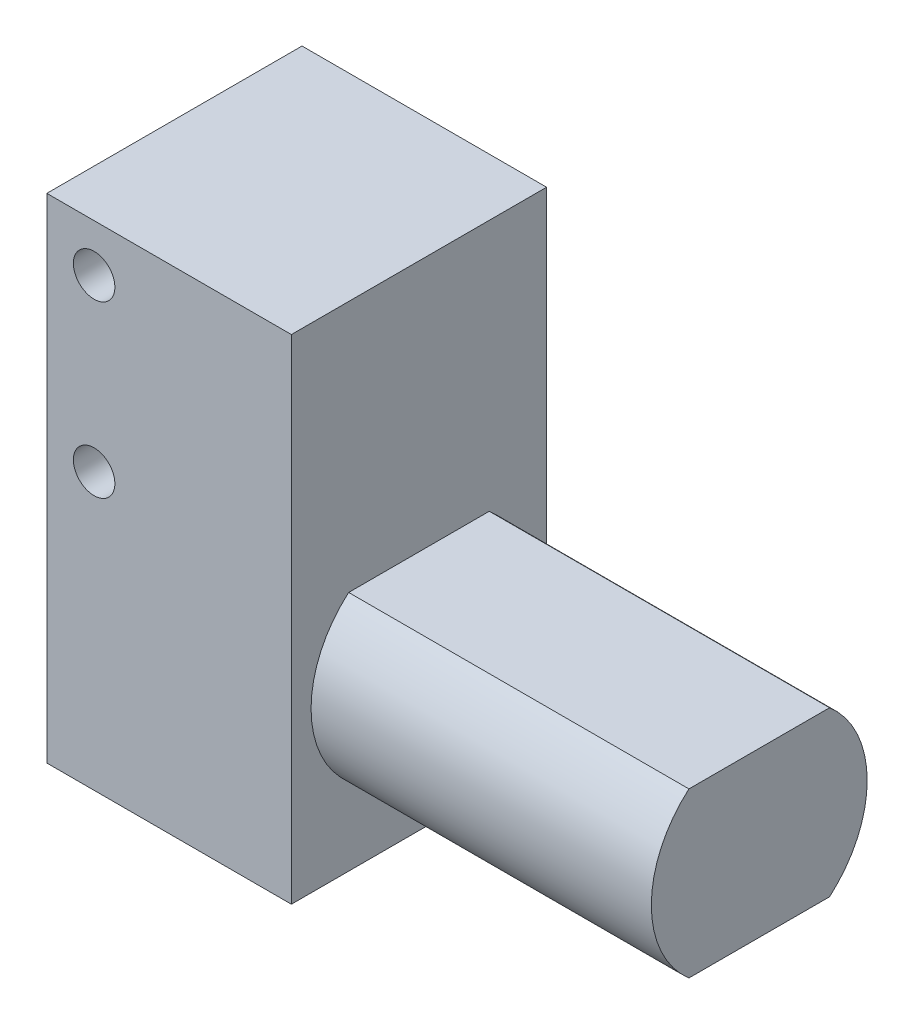
from build123d import *

# Parameters (mm, degrees)
SKETCH1_W               = 23
SKETCH1_H               = 46.4
BOSS_EXTRUDE1_DEPTH     = 12
SKETCH6_R               = 1.95
CUT_EXTRUDE1_DEPTH      = 5.5
SKETCH7_R               = 2.7
BOSS_EXTRUDE2_DEPTH     = 9
SKETCH8_W               = 7
SKETCH8_H               = 0.95
CUT_EXTRUDE2_DEPTH      = 47.4
SKETCH9_R               = 1.95
CUT_EXTRUDE3_DEPTH      = 5.5
SKETCH10_R              = 10.15
BOSS_EXTRUDE3_DEPTH     = 32
SKETCH11_W              = 32
SKETCH11_H              = 2.45
CUT_EXTRUDE4_DEPTH      = 13
CUT_EXTRUDE4_DEPTH_BACK = 13
SKETCH12_W              = 3
SKETCH12_H              = 9
CUT_EXTRUDE5_DEPTH      = 5


with BuildPart() as part:
    # Sketch1 → Boss-Extrude1 (new body, symmetric)
    with BuildSketch(Plane.XY):
        with Locations((11.5, 23.2)):
            Rectangle(SKETCH1_W, SKETCH1_H)
    extrude(amount=BOSS_EXTRUDE1_DEPTH, both=True)

    # Sketch6 → Cut-Extrude1 (cut)
    with BuildSketch(Plane.XY.offset(12)):
        with Locations((4.45, 41.95)):
            Circle(SKETCH6_R)
        with Locations((4.45, 25.95)):
            Circle(SKETCH6_R)
    cut_extrude1 = extrude(amount=-CUT_EXTRUDE1_DEPTH, mode=Mode.SUBTRACT)

    # Mirror1: Cut-Extrude1 across plane
    add(cut_extrude1.mirror(Plane.XY), mode=Mode.SUBTRACT)

    # Sketch7 → Boss-Extrude2 (add)
    with BuildSketch(Plane.ZY):
        with Locations((0, 34.2)):
            Circle(SKETCH7_R)
    extrude(amount=BOSS_EXTRUDE2_DEPTH)

    # Sketch8 → Cut-Extrude2 (cut, through all)
    with BuildSketch(Plane(origin=(0, 0, 0), x_dir=(1, 0, 0), z_dir=(0, 1, 0))):
        with Locations((-5.5, 2.225)):
            Rectangle(SKETCH8_W, SKETCH8_H)
        with Locations((-5.5, -2.225)):
            Rectangle(SKETCH8_W, SKETCH8_H)
    extrude(amount=CUT_EXTRUDE2_DEPTH, mode=Mode.SUBTRACT)

    # Sketch9 → Cut-Extrude3 (cut)
    with BuildSketch(Plane.ZY):
        with Locations((-8, 10.45)):
            Circle(SKETCH9_R)
        with Locations((8, 10.45)):
            Circle(SKETCH9_R)
    extrude(amount=-CUT_EXTRUDE3_DEPTH, mode=Mode.SUBTRACT)

    # Sketch10 → Boss-Extrude3 (add)
    with BuildSketch(Plane(origin=(23, 0, 0), x_dir=(0, 0, -1), z_dir=(1, 0, 0))):
        with Locations((0, 15)):
            Circle(SKETCH10_R)
    extrude(amount=BOSS_EXTRUDE3_DEPTH)

    # Sketch11 → Cut-Extrude4 (cut, two sides)
    with BuildSketch(Plane.XY) as cut_extrude4_sk:
        with Locations((39, 23.925)):
            Rectangle(SKETCH11_W, SKETCH11_H)
        with Locations((39, 6.075)):
            Rectangle(SKETCH11_W, SKETCH11_H)
    extrude(amount=CUT_EXTRUDE4_DEPTH, mode=Mode.SUBTRACT)
    extrude(cut_extrude4_sk.sketch, amount=-CUT_EXTRUDE4_DEPTH_BACK, mode=Mode.SUBTRACT)

    # Sketch12 → Cut-Extrude5 (cut)
    with BuildSketch(Plane.XZ):
        with Locations((14.5, 0)):
            Rectangle(SKETCH12_W, SKETCH12_H)
    extrude(amount=-CUT_EXTRUDE5_DEPTH, mode=Mode.SUBTRACT)


solid = part.part
